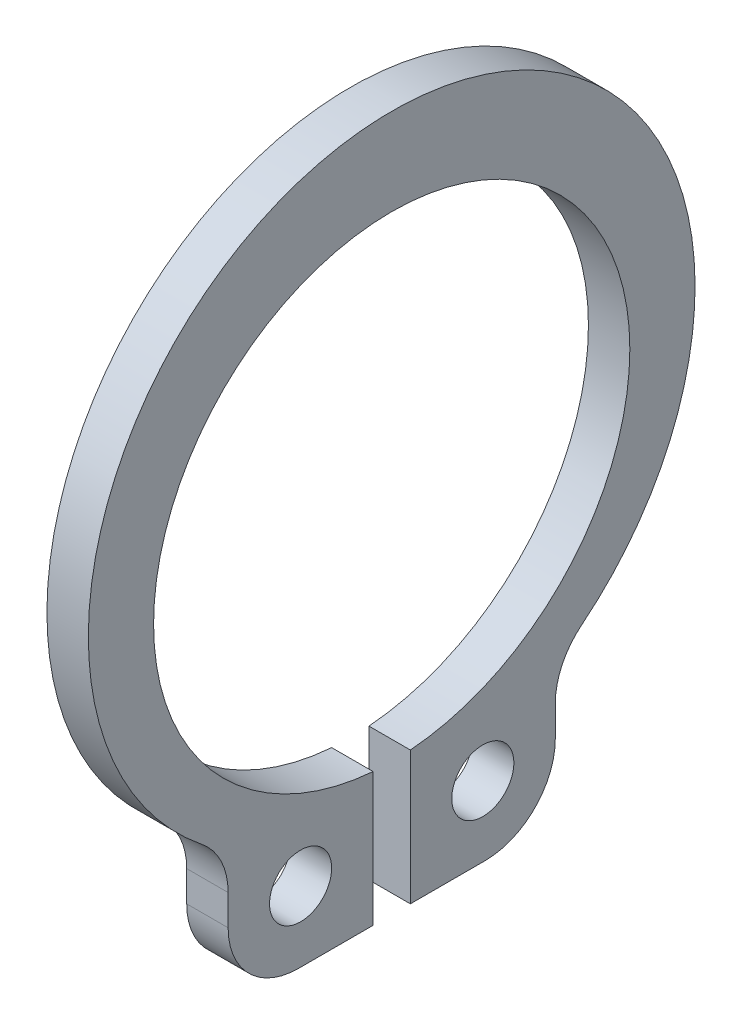
from build123d import *

# Parameters (mm, degrees)
EXTRUDE_1_DEPTH      = 0.5
EXTRUDE_1_DEPTH_BACK = 0.5
SKETCH_1_R           = 0.75


with BuildPart() as part:
    # ｽｹｯﾁ1 → ﾎﾞｽ - 押し出し1 (new, two sides: drawn at the far end of the back side and taken through both)
    with BuildSketch(Plane(origin=(0, 0, 0), x_dir=(0, 0, -1), z_dir=(1, 0, 0)).offset(-EXTRUDE_1_DEPTH_BACK)):
        with BuildLine():
            Line((-3.95, -6.512622113), (-3.95, -7.25))
            ThreePointArc((-3.95, -7.25), (-3.452081528, -8.452081528), (-2.25, -8.95))
            Line((-2.25, -8.95), (-0.45, -8.95))
            Line((-0.45, -8.95), (-0.45, -5.732364259))
            ThreePointArc((-0.45, -5.732364259), (0, 5.75), (0.45, -5.732364259))
            Line((0.45, -5.732364259), (0.45, -8.95))
            Line((0.45, -8.95), (2.25, -8.95))
            ThreePointArc((2.25, -8.95), (3.452081528, -8.452081528), (3.95, -7.25))
            Line((3.95, -7.25), (3.95, -6.512622113))
            ThreePointArc((3.95, -6.512622113), (4.117151006, -5.777520785), (4.585734072, -5.186975842))
            ThreePointArc((4.585734072, -5.186975842), (0, 7.85), (-4.585734072, -5.186975842))
            ThreePointArc((-4.585734072, -5.186975842), (-4.117151006, -5.777520785), (-3.95, -6.512622113))
        make_face()
        with Locations((2.2, -7.25)):
            Circle(SKETCH_1_R, mode=Mode.SUBTRACT)
        with Locations((-2.2, -7.25)):
            Circle(SKETCH_1_R, mode=Mode.SUBTRACT)
    extrude(amount=EXTRUDE_1_DEPTH + EXTRUDE_1_DEPTH_BACK)


solid = part.part
